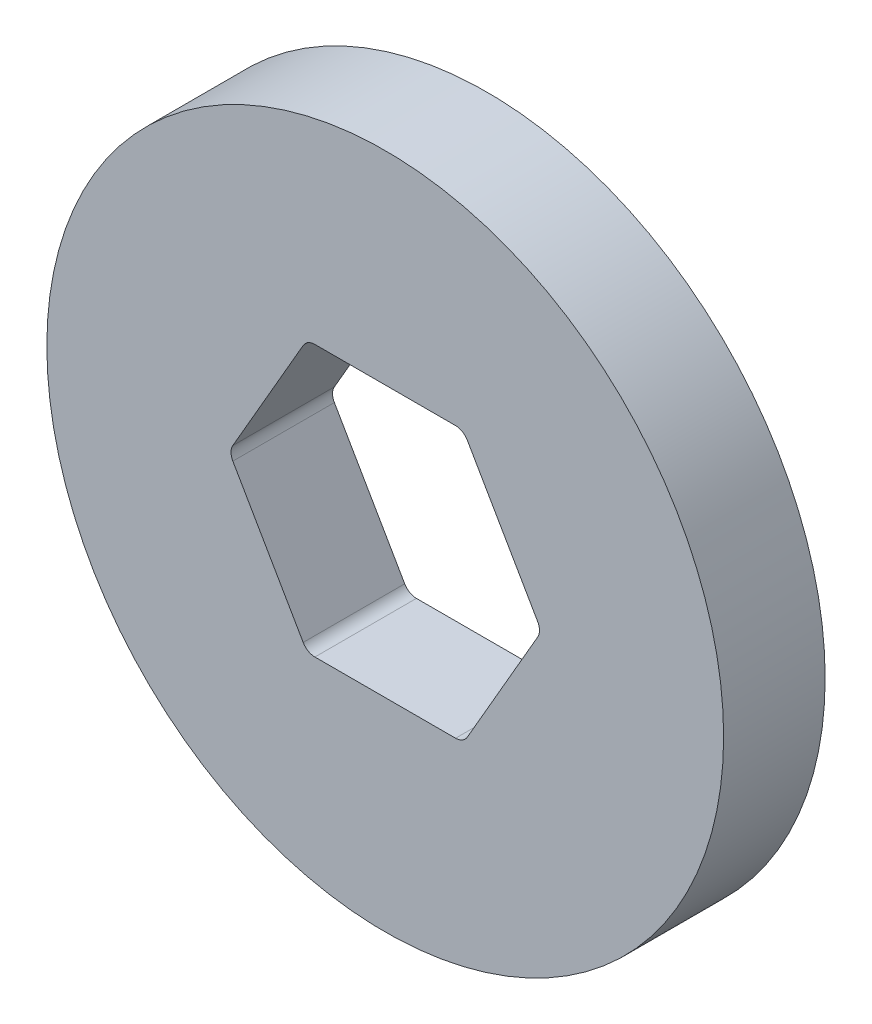
from build123d import *

# Parameters (mm, degrees)
SKETCH1_R           = 50
BOSS_EXTRUDE2_DEPTH = 15
FILLET1_R           = 2


with BuildPart() as part:
    # Sketch1 → Boss-Extrude2 (new body)
    with BuildSketch(Plane.XY):
        Circle(SKETCH1_R)
        Polygon((23.094010768, 0), (11.547005384, 20), (-11.547005384, 20), (-23.094010768, 0), (-11.547005384, -20), (11.547005384, -20), align=None, mode=Mode.SUBTRACT)
    extrude(amount=BOSS_EXTRUDE2_DEPTH)

    # Fillet1
    fillet1_edges = [part.edges().sort_by_distance(p)[0] for p in [
        (23.094010768, 0, 7.5),
        (11.547005384, 20, 7.5),
        (-11.547005384, 20, 7.5),
        (-23.094010768, 0, 7.5),
        (-11.547005384, -20, 7.5),
        (11.547005384, -20, 7.5),
    ]]
    fillet(fillet1_edges, radius=FILLET1_R)


solid = part.part
